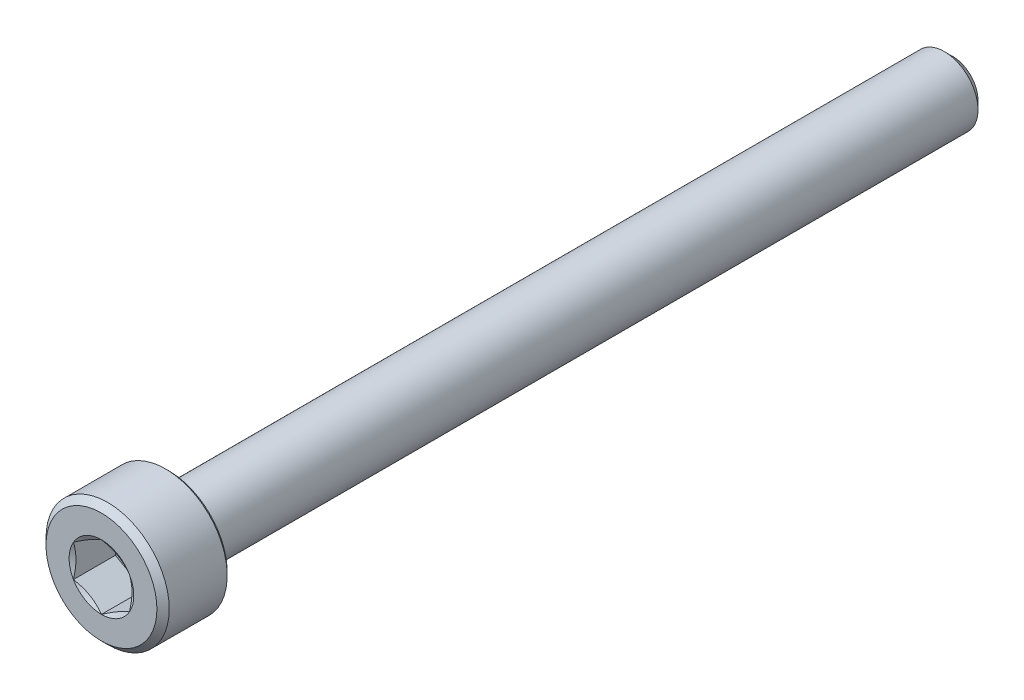
from build123d import *

# Parameters (mm, degrees)
CUT_EXTRUDE1_DEPTH = 1.875
CHAMFER1_SIZE      = 0.275
CHAMFER2_SIZE      = 0.1375
CHAMFER3_SIZE      = 0.375


with BuildPart() as part:
    # Sketch2 → Revolve1 (revolve)
    with BuildSketch(Plane(origin=(0, 0, 0), x_dir=(0, 0, -1), z_dir=(1, 0, 0))):
        Polygon((-19, 2.75), (-16, 2.75), (-16, 1.5), (19, 1.5), (19, 0), (-19, 0), align=None)
    revolve(axis=Axis((0, 0, -19), (0, 0, 1)))

    # Sketch4 → Cut-Extrude1 (cut)
    with BuildSketch(Plane.XY.offset(19)):
        Polygon((0, 1.443375673), (-1.25, 0.721687836), (-1.25, -0.721687836), (0, -1.443375673), (1.25, -0.721687836), (1.25, 0.721687836), align=None)
    extrude(amount=-CUT_EXTRUDE1_DEPTH, mode=Mode.SUBTRACT)

    # Cut-Extrude2 cone 1 section (through the dimple's axis) → Cut-Extrude2 (revolve, cut)
    with BuildSketch(Plane(origin=(0, 0, 19), x_dir=(0, -1, 0), z_dir=(1, 0, 0))):
        Polygon((0, 0), (1.443375673, 0), (0, 0.833333333), align=None)
    revolve(axis=Axis((0, 0, 19), (0, 0, -1)), mode=Mode.SUBTRACT)

    # Chamfer1
    chamfer1_edges = [part.edges().sort_by_distance(p)[0] for p in [
        (0, -2.75, 19),
    ]]
    chamfer(chamfer1_edges, length=CHAMFER1_SIZE)

    # Chamfer2
    chamfer2_edges = [part.edges().sort_by_distance(p)[0] for p in [
        (0, -2.75, 16),
    ]]
    chamfer(chamfer2_edges, length=CHAMFER2_SIZE)

    # Chamfer3
    chamfer3_edges = [part.edges().sort_by_distance(p)[0] for p in [
        (0, -1.5, -19),
    ]]
    chamfer(chamfer3_edges, length=CHAMFER3_SIZE)


solid = part.part
